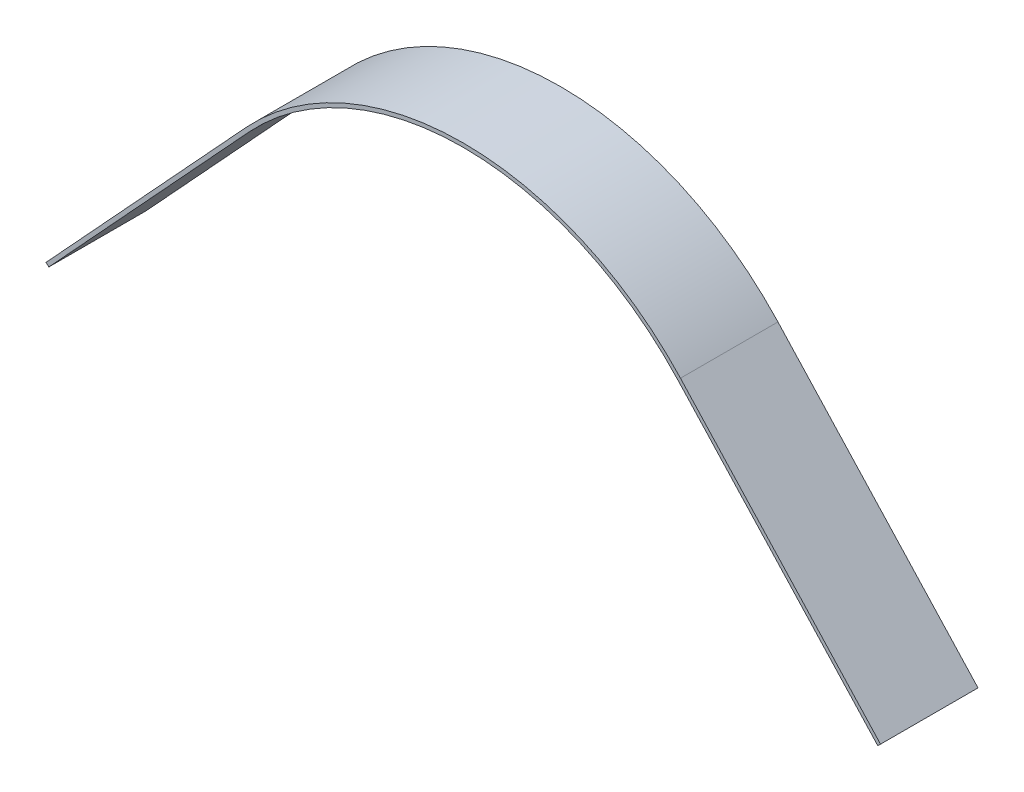
from build123d import *

# Parameters (mm, degrees)
EXTRUDE_THIN1_DEPTH = 12.7


with BuildPart() as part:
    # Sketch1 → Extrude-Thin1 (new body, symmetric)
    with BuildSketch(Plane.XY):
        with BuildLine():
            Line((108, -5), (55.866925555, 51.525591982))
            ThreePointArc((55.866925555, 51.525591982), (0, 76), (-55.866925555, 51.525591982))
            Line((-55.866925555, 51.525591982), (-108, -5))
            Line((-108, -5), (-108.735091126, -4.322031684))
            Line((-108.735091126, -4.322031684), (-56.60201668, 52.203560297))
            ThreePointArc((-56.60201668, 52.203560297), (0, 77), (56.60201668, 52.203560297))
            Line((56.60201668, 52.203560297), (108.735091126, -4.322031684))
            Line((108.735091126, -4.322031684), (108, -5))
        make_face()
    extrude(amount=EXTRUDE_THIN1_DEPTH, both=True)


solid = part.part
